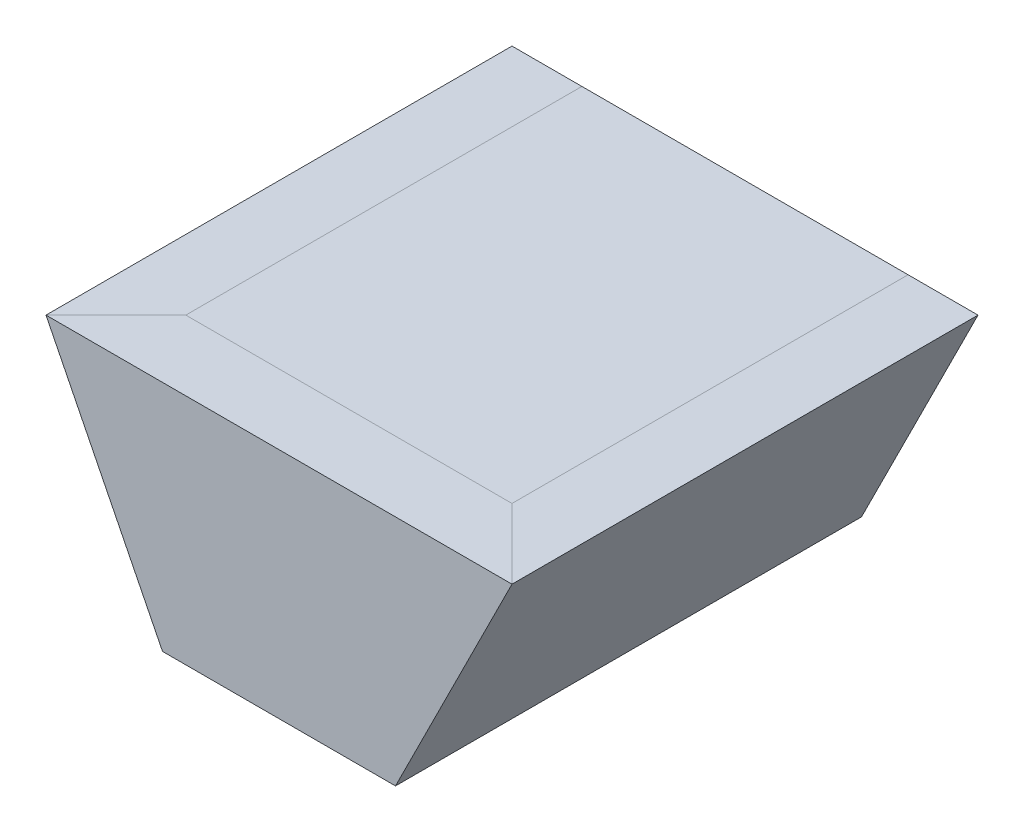
from build123d import *

# Parameters (mm, degrees)
AUFSATZ_LINEAR_AUSTRAGEN1_DEPTH = 200


with BuildPart() as part:
    # Skizze1 → Aufsatz-Linear austragen1 (new body)
    with BuildSketch(Plane.XY):
        Polygon((0, 0), (50, -100), (150, -100), (200, 0), align=None)
    extrude(amount=-AUFSATZ_LINEAR_AUSTRAGEN1_DEPTH)


solid = part.part
